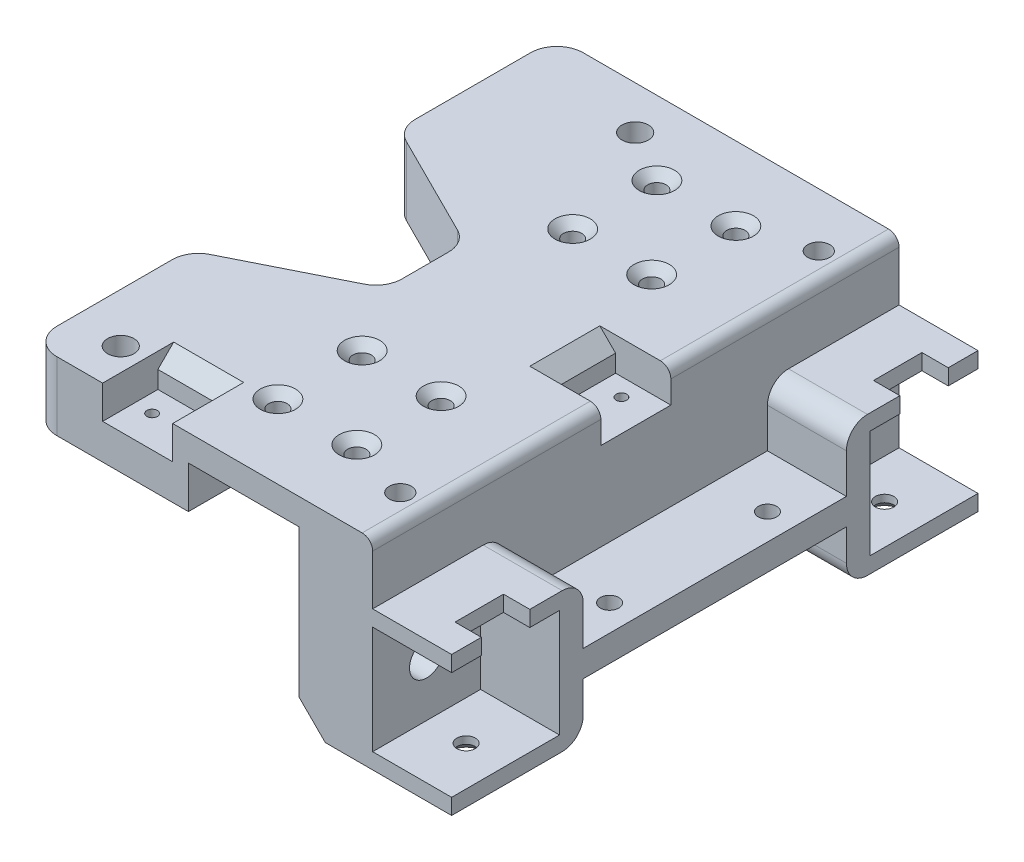
from build123d import *

# Parameters (mm, degrees)
SKETCH1_W           = 21
SKETCH1_H           = 100
SKETCH1_R           = 1.75
BOSS_EXTRUDE1_DEPTH = 5
SKETCH2_W           = 100
SKETCH2_H           = 38
BOSS_EXTRUDE2_DEPTH = 14
SKETCH3_W           = 50
SKETCH3_H           = 5
BOSS_EXTRUDE3_DEPTH = 15
SKETCH4_R           = 1.75
CUT_EXTRUDE1_DEPTH  = 16
BOSS_EXTRUDE6_DEPTH = 15
SKETCH9_R           = 3.25
CUT_EXTRUDE3_DEPTH  = 36
SKETCH10_R          = 5.25
CUT_EXTRUDE4_DEPTH  = 9
CUT_EXTRUDE5_REACH  = 28.5
SKETCH11_W          = 5
SKETCH11_H          = 9.2
SKETCH12_R          = 1.75
CUT_EXTRUDE6_DEPTH  = 4
SKETCH13_W          = 100
SKETCH13_H          = 13
BOSS_EXTRUDE7_DEPTH = 30
SKETCH14_R          = 2.5
CUT_EXTRUDE7_DEPTH  = 39
CUT_EXTRUDE8_DEPTH  = 5
SKETCH16_R          = 2.1
CUT_EXTRUDE9_DEPTH  = 4
CHAMFER1_SIZE       = 1.6
CUT_EXTRUDE10_DEPTH = 39
CHAMFER2_SIZE       = 1.6
CHAMFER3_SIZE       = 5
SKETCH18_R          = 1.75
CUT_EXTRUDE11_DEPTH = 4
FILLET1_R           = 5
FILLET2_R           = 4
SKETCH19_W          = 13.3
SKETCH19_H          = 6.3
CUT_EXTRUDE12_DEPTH = 10.5
SKETCH20_R          = 1
CUT_EXTRUDE13_DEPTH = 3
CHAMFER4_SIZE       = 3
FILLET3_R           = 2
SKETCH22_W          = 13.3
SKETCH22_H          = 10.5
CUT_EXTRUDE14_DEPTH = 6.3
SKETCH23_R          = 1
CUT_EXTRUDE15_DEPTH = 3
CHAMFER5_SIZE       = 3


with BuildPart() as part:
    # Sketch1 → Boss-Extrude1 (new body)
    with BuildSketch(Plane(origin=(0, 0, 0), x_dir=(1, 0, 0), z_dir=(0, 1, 0))):
        Rectangle(SKETCH1_W, SKETCH1_H)
        with Locations((-7.5, 36)):
            Circle(SKETCH1_R, mode=Mode.SUBTRACT)
        with Locations((7.5, 36)):
            Circle(SKETCH1_R, mode=Mode.SUBTRACT)
        with Locations((-7.5, 20)):
            Circle(SKETCH1_R, mode=Mode.SUBTRACT)
        with Locations((7.5, 20)):
            Circle(SKETCH1_R, mode=Mode.SUBTRACT)
        with Locations((7.5, -20)):
            Circle(SKETCH1_R, mode=Mode.SUBTRACT)
        with Locations((-7.5, -20)):
            Circle(SKETCH1_R, mode=Mode.SUBTRACT)
        with Locations((7.5, -36)):
            Circle(SKETCH1_R, mode=Mode.SUBTRACT)
        with Locations((-7.5, -36)):
            Circle(SKETCH1_R, mode=Mode.SUBTRACT)
    extrude(amount=BOSS_EXTRUDE1_DEPTH)

    # Sketch2 → Boss-Extrude2 (add)
    with BuildSketch(Plane(origin=(10.5, 0, 0), x_dir=(0, 0, -1), z_dir=(1, 0, 0))):
        with Locations((0, -14)):
            Rectangle(SKETCH2_W, SKETCH2_H)
    extrude(amount=BOSS_EXTRUDE2_DEPTH)

    # Sketch3 → Boss-Extrude3 (add)
    with BuildSketch(Plane(origin=(24.5, 0, 0), x_dir=(0, 0, -1), z_dir=(1, 0, 0))):
        with Locations((0, -20.5)):
            Rectangle(SKETCH3_W, SKETCH3_H)
    extrude(amount=BOSS_EXTRUDE3_DEPTH)

    # Sketch4 → Cut-Extrude1 (cut, through all)
    with BuildSketch(Plane(origin=(0, -18, 0), x_dir=(1, 0, 0), z_dir=(0, 1, 0))):
        with Locations((34.5, 15)):
            Circle(SKETCH4_R)
        with Locations((34.5, -15)):
            Circle(SKETCH4_R)
    extrude(amount=-CUT_EXTRUDE1_DEPTH, mode=Mode.SUBTRACT)

    # Sketch8 → Boss-Extrude6 (add)
    with BuildSketch(Plane(origin=(24.5, 0, 0), x_dir=(0, 0, -1), z_dir=(1, 0, 0))):
        Polygon((-50, -6.5), (-25, -6.5), (-25, -33), (-50, -33), (-50, -30), (-29.5, -30), (-29.5, -9.5), (-50, -9.5), align=None)
        Polygon((29.5, -30), (29.5, -9.5), (50, -9.5), (50, -6.5), (25, -6.5), (25, -33), (50, -33), (50, -30), align=None)
    extrude(amount=BOSS_EXTRUDE6_DEPTH)

    # Sketch9 → Cut-Extrude3 (cut, through all)
    with BuildSketch(Plane(origin=(24.5, 0, 0), x_dir=(0, 0, -1), z_dir=(1, 0, 0))):
        with Locations((-39.75, -19.75)):
            Circle(SKETCH9_R)
        with Locations((39.75, -19.75)):
            Circle(SKETCH9_R)
    extrude(amount=-CUT_EXTRUDE3_DEPTH, mode=Mode.SUBTRACT)

    # Sketch10 → Cut-Extrude4 (cut)
    with BuildSketch(Plane.ZY.offset(-10.5)):
        with Locations((-39.75, -19.75)):
            Circle(SKETCH10_R)
        with Locations((39.75, -19.75)):
            Circle(SKETCH10_R)
    extrude(amount=-CUT_EXTRUDE4_DEPTH, mode=Mode.SUBTRACT)

    # Sketch11 → Cut-Extrude5 (cut, up to next)
    with BuildSketch(Plane(origin=(0, -6.5, 0), x_dir=(1, 0, 0), z_dir=(0, 1, 0)), mode=Mode.PRIVATE) as cut_extrude5_sk1:
        with Locations((37, -39.75)):
            Rectangle(SKETCH11_W, SKETCH11_H)
    cut_extrude5_tool1 = extrude(cut_extrude5_sk1.sketch, amount=-CUT_EXTRUDE5_REACH, mode=Mode.PRIVATE) & part.part
    add(cut_extrude5_tool1.solids().sort_by_distance((37, -6.5, 39.75))[0], mode=Mode.SUBTRACT)
    # Sketch11 → Cut-Extrude5 (cut, up to next)
    with BuildSketch(Plane(origin=(0, -6.5, 0), x_dir=(1, 0, 0), z_dir=(0, 1, 0)), mode=Mode.PRIVATE) as cut_extrude5_sk2:
        with Locations((37, 39.75)):
            Rectangle(SKETCH11_W, SKETCH11_H)
    cut_extrude5_tool2 = extrude(cut_extrude5_sk2.sketch, amount=-CUT_EXTRUDE5_REACH, mode=Mode.PRIVATE) & part.part
    add(cut_extrude5_tool2.solids().sort_by_distance((37, -6.5, -39.75))[0], mode=Mode.SUBTRACT)

    # Sketch12 → Cut-Extrude6 (cut, through all)
    with BuildSketch(Plane(origin=(0, -30, 0), x_dir=(1, 0, 0), z_dir=(0, 1, 0))):
        with Locations((32, -39.75)):
            Circle(SKETCH12_R)
        with Locations((32, 39.75)):
            Circle(SKETCH12_R)
    extrude(amount=-CUT_EXTRUDE6_DEPTH, mode=Mode.SUBTRACT)

    # Sketch13 → Boss-Extrude7 (add)
    with BuildSketch(Plane.ZY.offset(10.5)):
        with Locations((0, -1.5)):
            Rectangle(SKETCH13_W, SKETCH13_H)
    extrude(amount=BOSS_EXTRUDE7_DEPTH)

    # Sketch14 → Cut-Extrude7 (cut, through all)
    with BuildSketch(Plane(origin=(0, 5, 0), x_dir=(1, 0, 0), z_dir=(0, 1, 0))):
        with Locations((-17.4375, 41.8075)):
            Circle(SKETCH14_R)
        with Locations((-31.15, -42.205)):
            Circle(SKETCH14_R)
    extrude(amount=-CUT_EXTRUDE7_DEPTH, mode=Mode.SUBTRACT)

    # Sketch15 → Cut-Extrude8 (cut)
    with BuildSketch(Plane.XZ.offset(8)):
        Polygon((-27.05, 44.572136104), (-31.15, 46.939272207), (-35.25, 44.572136104), (-35.25, 39.837863896), (-31.15, 37.470727793), (-27.05, 39.837863896), align=None)
        Polygon((-13.3375, -44.174636104), (-13.3375, -39.440363896), (-17.4375, -37.073227793), (-21.5375, -39.440363896), (-21.5375, -44.174636104), (-17.4375, -46.541772207), align=None)
    extrude(amount=-CUT_EXTRUDE8_DEPTH, mode=Mode.SUBTRACT)

    # Sketch16 → Cut-Extrude9 (cut)
    with BuildSketch(Plane(origin=(0, 5, 0), x_dir=(1, 0, 0), z_dir=(0, 1, 0))):
        with Locations((19.5, 39.75)):
            Circle(SKETCH16_R)
        with Locations((19.5, -39.75)):
            Circle(SKETCH16_R)
    extrude(amount=-CUT_EXTRUDE9_DEPTH, mode=Mode.SUBTRACT)

    # Chamfer1
    chamfer1_edges = [part.edges().sort_by_distance(p)[0] for p in [
        (-9.25, 5, -36),
        (5.75, 5, -36),
        (-9.25, 5, -20),
        (5.75, 5, -20),
        (5.75, 5, 20),
        (-9.25, 5, 20),
        (5.75, 5, 36),
        (-9.25, 5, 36),
    ]]
    chamfer(chamfer1_edges, length=CHAMFER1_SIZE)

    # Sketch17 → Cut-Extrude10 (cut, through all)
    with BuildSketch(Plane(origin=(0, 5, 0), x_dir=(1, 0, 0), z_dir=(0, 1, 0))):
        Polygon((-40.5, 20), (-15.5, 7.5), (-15.5, -7.5), (-40.5, -20), align=None)
    extrude(amount=-CUT_EXTRUDE10_DEPTH, mode=Mode.SUBTRACT)

    # Chamfer2
    chamfer2_edges = [part.edges().sort_by_distance(p)[0] for p in [
        (30.25, -33, 39.75),
        (30.25, -33, -39.75),
    ]]
    chamfer(chamfer2_edges, length=CHAMFER2_SIZE)

    # Chamfer3
    chamfer3_edges = [part.edges().sort_by_distance(p)[0] for p in [
        (10.5, -33, 0),
    ]]
    chamfer(chamfer3_edges, length=CHAMFER3_SIZE)

    # Sketch18 → Cut-Extrude11 (cut)
    with BuildSketch(Plane(origin=(0, 1, 0), x_dir=(1, 0, 0), z_dir=(0, 1, 0))):
        with Locations((19.5, 39.75)):
            Circle(SKETCH18_R)
        with Locations((19.5, -39.75)):
            Circle(SKETCH18_R)
    extrude(amount=-CUT_EXTRUDE11_DEPTH, mode=Mode.SUBTRACT)

    # Fillet1
    fillet1_edges = [part.edges().sort_by_distance(p)[0] for p in [
        (-40.5, -1.5, -50),
        (-40.5, -1.5, 50),
        (-40.5, -1.5, 20),
        (-40.5, -1.5, -20),
        (-15.5, -1.5, -7.5),
        (-15.5, -1.5, 7.5),
    ]]
    fillet(fillet1_edges, radius=FILLET1_R)

    # Fillet2
    fillet2_edges = [part.edges().sort_by_distance(p)[0] for p in [
        (32, -6.5, -25),
        (32, -33, -25),
        (32, -33, 25),
        (32, -6.5, 25),
    ]]
    fillet(fillet2_edges, radius=FILLET2_R)

    # Sketch19 → Cut-Extrude12 (cut)
    with BuildSketch(Plane(origin=(24.5, 0, 0), x_dir=(0, 0, -1), z_dir=(1, 0, 0))):
        with Locations((0, 1.85)):
            Rectangle(SKETCH19_W, SKETCH19_H)
    extrude(amount=-CUT_EXTRUDE12_DEPTH, mode=Mode.SUBTRACT)

    # Sketch20 → Cut-Extrude13 (cut)
    with BuildSketch(Plane(origin=(0, -1.3, 0), x_dir=(1, 0, 0), z_dir=(0, 1, 0))):
        with Locations((18.5, 3.25)):
            Circle(SKETCH20_R)
        with Locations((18.5, -3.25)):
            Circle(SKETCH20_R)
    extrude(amount=-CUT_EXTRUDE13_DEPTH, mode=Mode.SUBTRACT)

    # Chamfer4
    chamfer4_edges = [part.edges().sort_by_distance(p)[0] for p in [
        (14, 5, 0),
    ]]
    chamfer(chamfer4_edges, length=CHAMFER4_SIZE)

    # Fillet3
    fillet3_edges = [part.edges().sort_by_distance(p)[0] for p in [
        (24.5, 5, 28.325),
        (24.5, 5, -28.325),
    ]]
    fillet(fillet3_edges, radius=FILLET3_R)

    # Sketch22 → Cut-Extrude14 (cut)
    with BuildSketch(Plane(origin=(0, 5, 0), x_dir=(1, 0, 0), z_dir=(0, 1, 0))):
        with Locations((-20.15, -44.75)):
            Rectangle(SKETCH22_W, SKETCH22_H)
    extrude(amount=-CUT_EXTRUDE14_DEPTH, mode=Mode.SUBTRACT)

    # Sketch23 → Cut-Extrude15 (cut)
    with BuildSketch(Plane(origin=(0, -1.3, 0), x_dir=(1, 0, 0), z_dir=(0, 1, 0))):
        with Locations((-23.4, -44)):
            Circle(SKETCH23_R)
        with Locations((-16.9, -44)):
            Circle(SKETCH23_R)
    extrude(amount=-CUT_EXTRUDE15_DEPTH, mode=Mode.SUBTRACT)

    # Chamfer5
    chamfer5_edges = [part.edges().sort_by_distance(p)[0] for p in [
        (-20.15, 5, 39.5),
    ]]
    chamfer(chamfer5_edges, length=CHAMFER5_SIZE)


solid = part.part
